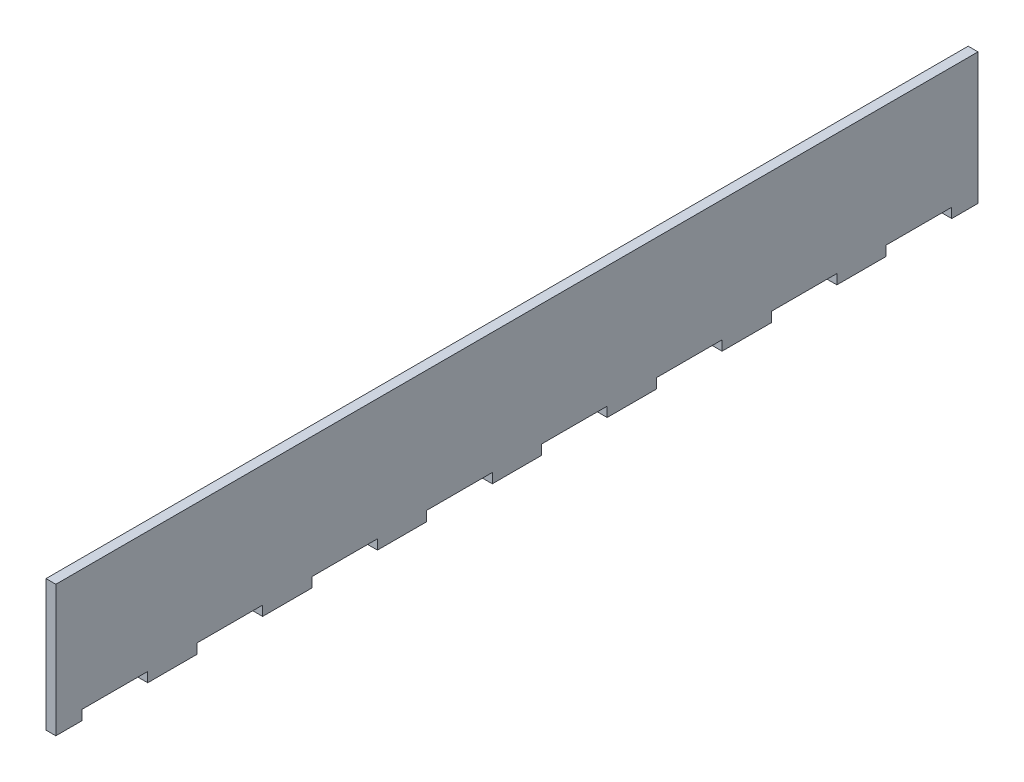
from build123d import *

# Parameters (mm, degrees)
BOSS_EXTRUDE1_DEPTH = 3


with BuildPart() as part:
    # Sketch1 → Boss-Extrude1 (new body)
    with BuildSketch(Plane(origin=(0, 0, 0), x_dir=(0, 0, -1), z_dir=(1, 0, 0))):
        Polygon((28, 0), (43, 0), (43, 3), (63, 3), (63, 0), (78, 0), (78, 3), (98, 3), (98, 0), (113, 0), (113, 3), (133, 3), (133, 0), (148, 0), (148, 3), (168, 3), (168, 0), (183, 0), (183, 3), (203, 3), (203, 0), (218, 0), (218, 3), (238, 3), (238, 0), (253, 0), (253, 3), (273, 3), (273, 0), (281, 0), (281, 40), (0, 40), (0, 0), (8, 0), (8, 3), (28, 3), align=None)
    extrude(amount=BOSS_EXTRUDE1_DEPTH)


solid = part.part
